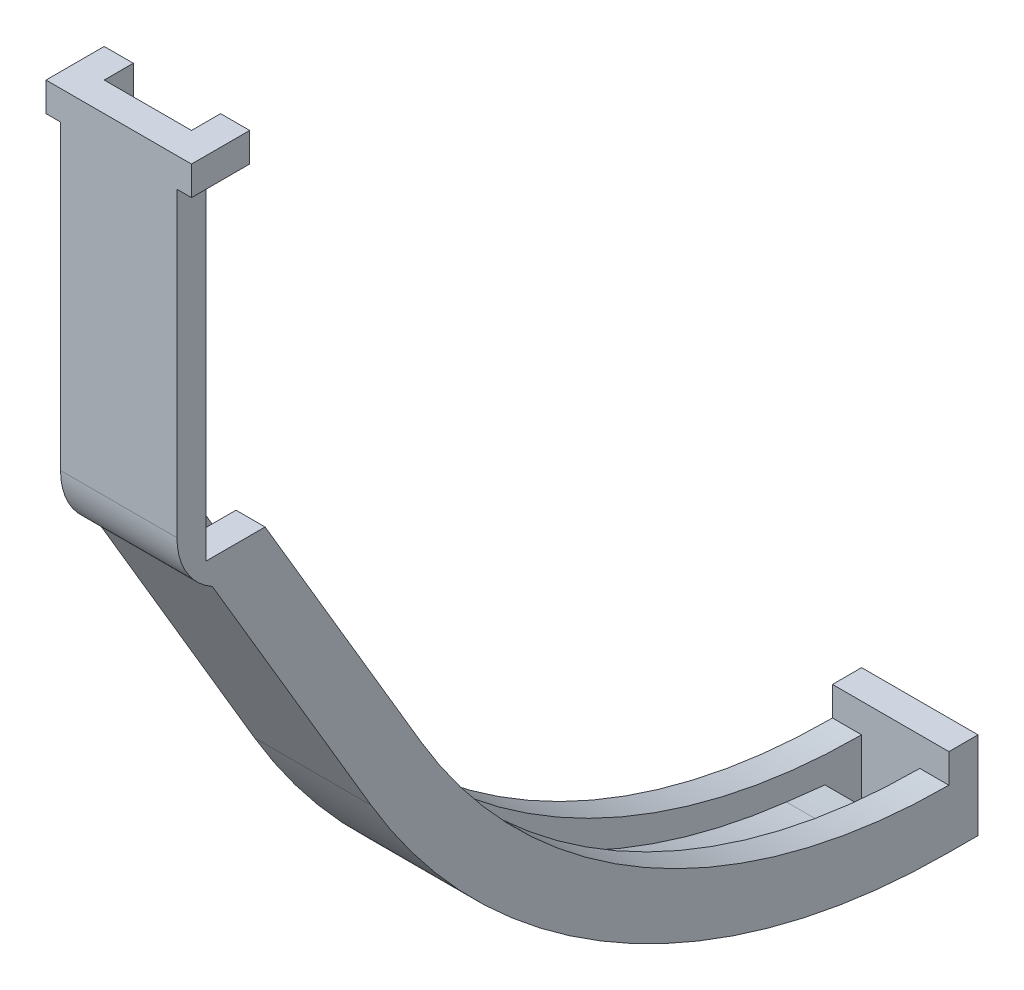
from build123d import *

# Parameters (mm, degrees)
SKETCH5_W           = 12.880016042
SKETCH5_H           = 15.834691301
CUT_EXTRUDE2_DEPTH  = 7.62
CUT_EXTRUDE6_REACH  = 62
SKETCH11_W          = 3.175
SKETCH11_H          = 3.175
BOSS_EXTRUDE1_DEPTH = 6.35
CUT_EXTRUDE4_DEPTH  = 3.175
CUT_EXTRUDE7_DEPTH  = 40.64
BOSS_EXTRUDE3_DEPTH = 12.7
SKETCH19_W          = 21.319602533
SKETCH19_H          = 36.10119369
CUT_EXTRUDE10_DEPTH = 13.7
SKETCH15_W          = 6.35
SKETCH15_H          = 3.175
BOSS_EXTRUDE2_DEPTH = 1.5875
SKETCH20_W          = 6.35
SKETCH20_H          = 4
CUT_EXTRUDE11_DEPTH = 108.95


with BuildPart() as part:
    # Sketch2 → Revolve1 (revolve)
    with BuildSketch(Plane(origin=(0, 0, 0), x_dir=(0, 0, -1), z_dir=(1, 0, 0))):
        Polygon((0, -50.8), (-29.999999944, 0), (0, 0), align=None)
    revolve(axis=Axis((0, 0, 0), (0, -1, 0)))

    # Sketch4 → Cut-Revolve1 (revolve, cut)
    with BuildSketch(Plane(origin=(0, 0, 0), x_dir=(0, 0, -1), z_dir=(1, 0, 0))):
        Polygon((0, -45.72), (-24.919999944, 0), (0, 0), align=None)
    revolve(axis=Axis((0, 16.11457811, 0), (0, -1, 0)), mode=Mode.SUBTRACT)

    # Sketch5 → Cut-Extrude2 (cut, symmetric)
    with BuildSketch(Plane(origin=(0, 0, 0), x_dir=(0, 0, -1), z_dir=(1, 0, 0))):
        with Locations((0, -47.812265381)):
            Rectangle(SKETCH5_W, SKETCH5_H)
    extrude(amount=CUT_EXTRUDE2_DEPTH, both=True, mode=Mode.SUBTRACT)

    # Sketch11 → Cut-Extrude6 (cut, up to next)
    with BuildSketch(Plane.XY.offset(29.999999944), mode=Mode.PRIVATE) as cut_extrude6_sk1:
        with Locations((4.7625, -1.5875)):
            Rectangle(SKETCH11_W, SKETCH11_H)
    cut_extrude6_tool1 = extrude(cut_extrude6_sk1.sketch, amount=-CUT_EXTRUDE6_REACH, mode=Mode.PRIVATE) & part.part
    add(cut_extrude6_tool1.solids().sort_by_distance((4.7625, -1.5875, 30))[0], mode=Mode.SUBTRACT)
    # Sketch11 → Cut-Extrude6 (cut, up to next)
    with BuildSketch(Plane.XY.offset(29.999999944), mode=Mode.PRIVATE) as cut_extrude6_sk2:
        with Locations((-4.7625, -1.5875)):
            Rectangle(SKETCH11_W, SKETCH11_H)
    cut_extrude6_tool2 = extrude(cut_extrude6_sk2.sketch, amount=-CUT_EXTRUDE6_REACH, mode=Mode.PRIVATE) & part.part
    add(cut_extrude6_tool2.solids().sort_by_distance((-4.7625, -1.5875, 30))[0], mode=Mode.SUBTRACT)

    # Sketch6 → Boss-Extrude1 (add, symmetric)
    with BuildSketch(Plane(origin=(0, 0, 0), x_dir=(0, 0, -1), z_dir=(1, 0, 0))):
        with BuildLine():
            Line((0, -39.89491973), (-7.374618631, -39.89491973))
            Line((-7.374618631, -39.89491973), (11.56279342, -71.962270863))
            ThreePointArc((11.56279342, -71.962270863), (29.890602823, -92.707185326), (54.61, -105.165575141))
            ThreePointArc((54.61, -105.165575141), (64.513552335, -107.250553005), (74.61, -107.95))
            Line((74.61, -107.95), (77.785, -107.95))
            Line((77.785, -107.95), (77.785, -98.425))
            Line((77.785, -98.425), (74.61, -98.425))
            Line((74.61, -98.425), (74.61, -101.6))
            ThreePointArc((74.61, -101.6), (41.460280796, -92.804941633), (17.03053379, -68.733290336))
            Line((17.03053379, -68.733290336), (0, -39.89491973))
        make_face()
        Polygon((-30.934610553, 0), (-7.374618631, -39.89491973), (0, -39.89491973), (-23.559991923, 0), align=None)
    extrude(amount=BOSS_EXTRUDE1_DEPTH, both=True)

    # Sketch7 → Cut-Extrude4 (cut)
    with BuildSketch(Plane(origin=(0, 0, 0), x_dir=(0, 0, -1), z_dir=(1, 0, 0))):
        with BuildLine():
            Line((-3.175, -39.89491973), (14.676503495, -70.123465704))
            ThreePointArc((14.676503495, -70.123465704), (36.599939349, -93.039017482), (66.414189392, -103.849662572))
            ThreePointArc((66.414189392, -103.849662572), (70.51080038, -104.32379518), (74.61, -104.775))
            Line((74.61, -104.775), (74.61, -101.6))
            ThreePointArc((74.61, -101.6), (59.345071166, -99.83437787), (44.886242604, -94.630749287))
            ThreePointArc((44.886242604, -94.630749287), (29.078331812, -83.704237641), (17.03053379, -68.733290336))
            Line((17.03053379, -68.733290336), (-23.559991923, 0))
            Line((-23.559991923, 0), (-26.734991923, 0))
            Line((-26.734991923, 0), (-3.175, -39.89491973))
        make_face()
    cut_extrude4 = extrude(amount=-CUT_EXTRUDE4_DEPTH, mode=Mode.SUBTRACT)

    # Mirror1: Cut-Extrude4 across plane
    add(cut_extrude4.mirror(Plane(origin=(0, 0, 0), x_dir=(0, 0, 1), z_dir=(1, 0, 0))), mode=Mode.SUBTRACT)

    # Sketch9 → Cut-Revolve2 (revolve, cut)
    with BuildSketch(Plane(origin=(0, 0, 0), x_dir=(0, 0, -1), z_dir=(1, 0, 0))):
        Polygon((0, 0), (-24.9199908, 0), (-0.536470716, -39.89491973), (0, -39.89491973), align=None)
    revolve(axis=Axis((0, 16.11457811, 0), (0, -1, 0)), mode=Mode.SUBTRACT)

    # Sketch12 → Cut-Extrude7 (cut, symmetric)
    with BuildSketch(Plane.ZY):
        Polygon((30, 0), (-61.025869449, 0), (-61.025869449, -39.89491973), (-6.440008021, -39.89491973), (6.44000802, -39.89491973), (27.945214206, -3.175), align=None)
    extrude(amount=CUT_EXTRUDE7_DEPTH, both=True, mode=Mode.SUBTRACT)

    # Sketch18 → Boss-Extrude3 (add)
    with BuildSketch(Plane.ZY.offset(6.35)):
        with BuildLine():
            Line((6.44000802, -39.89491973), (6.44000802, 0))
            Line((6.44000802, 0), (9.61500802, 0))
            Line((9.61500802, 0), (9.61500802, -34.473639686))
            Line((9.61500802, -34.473639686), (9.61500802, -36.10119369))
            ThreePointArc((9.61500802, -36.10119369), (8.57844205, -39.89491973), (5.756782033, -42.634456374))
            Line((5.756782033, -42.634456374), (6.44000802, -41.477527034))
            Line((6.44000802, -41.477527034), (6.44000802, -39.89491973))
        make_face()
    extrude(amount=-BOSS_EXTRUDE3_DEPTH)

    # Sketch19 → Cut-Extrude10 (cut, through all)
    with BuildSketch(Plane.ZY.offset(6.35)):
        with Locations((20.274809287, -18.050596845)):
            Rectangle(SKETCH19_W, SKETCH19_H)
    extrude(amount=-CUT_EXTRUDE10_DEPTH, mode=Mode.SUBTRACT)

    # Sketch15 → Boss-Extrude2 (add, symmetric)
    with BuildSketch(Plane.ZY.offset(6.35)):
        with Locations((6.44000802, -1.5875)):
            Rectangle(SKETCH15_W, SKETCH15_H)
    boss_extrude2 = extrude(amount=BOSS_EXTRUDE2_DEPTH, both=True)

    # Mirror2: Boss-Extrude2 across plane
    add(boss_extrude2.mirror(Plane(origin=(0, 0, 0), x_dir=(0, 0, 1), z_dir=(1, 0, 0))))

    # Sketch20 → Cut-Extrude11 (cut, through all)
    with BuildSketch(Plane(origin=(0, 0, 0), x_dir=(1, 0, 0), z_dir=(0, 1, 0))):
        with Locations((0, 72.61)):
            Rectangle(SKETCH20_W, SKETCH20_H)
    extrude(amount=-CUT_EXTRUDE11_DEPTH, mode=Mode.SUBTRACT)


solid = part.part
